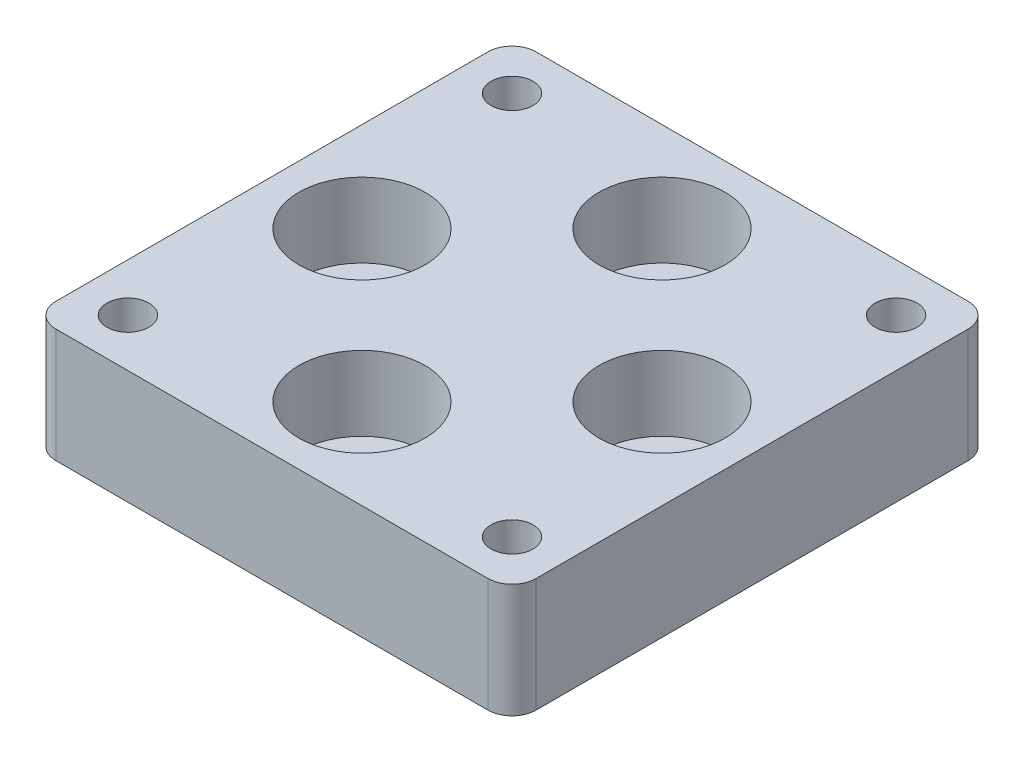
from build123d import *

# Parameters (mm, degrees)
SKETCH_1_W          = 40
SKETCH_1_H          = 40
SKETCH_1_R          = 1.75
SKETCH_1_R_2        = 3.1
EXTRUDE_1_DEPTH     = 9.5
FILLET_1_R          = 2
SKETCH_2_R          = 5.25
CUT_EXTRUDE_1_DEPTH = 6.2


with BuildPart() as part:
    # 草图1 → 凸台-拉伸1 (new body)
    with BuildSketch(Plane(origin=(0, 0, 0), x_dir=(1, 0, 0), z_dir=(0, 1, 0))):
        Rectangle(SKETCH_1_W, SKETCH_1_H)
        with Locations(Location((-16, 16, 0), (0, 0, 270))):  # turned: the seam where the file's is
            Circle(SKETCH_1_R, mode=Mode.SUBTRACT)
        with Locations(Location((16, 16, 0), (0, 0, 270))):  # turned: the seam where the file's is
            Circle(SKETCH_1_R, mode=Mode.SUBTRACT)
        with Locations(Location((-16, -16, 0), (0, 0, 270))):  # turned: the seam where the file's is
            Circle(SKETCH_1_R, mode=Mode.SUBTRACT)
        with Locations(Location((16, -16, 0), (0, 0, 270))):  # turned: the seam where the file's is
            Circle(SKETCH_1_R, mode=Mode.SUBTRACT)
        with Locations(Location((-12.5, 0, 0), (0, 0, 270))):  # turned: the seam where the file's is
            Circle(SKETCH_1_R_2, mode=Mode.SUBTRACT)
        with Locations(Location((12.5, 0, 0), (0, 0, 90))):  # turned: the seam where the file's is
            Circle(SKETCH_1_R_2, mode=Mode.SUBTRACT)
        with Locations(Location((0, 12.5, 0), (0, 0, 270))):  # turned: the seam where the file's is
            Circle(SKETCH_1_R_2, mode=Mode.SUBTRACT)
        with Locations(Location((0, -12.5, 0), (0, 0, 90))):  # turned: the seam where the file's is
            Circle(SKETCH_1_R_2, mode=Mode.SUBTRACT)
    extrude(amount=EXTRUDE_1_DEPTH)

    # 圆角1
    fillet_1_edges = [part.edges().sort_by_distance(p)[0] for p in [
        (20, 4.75, 20),
        (-20, 4.75, 20),
        (-20, 4.75, -20),
        (20, 4.75, -20),
    ]]
    fillet(fillet_1_edges, radius=FILLET_1_R)

    # 草图2 → 切除-拉伸1 (cut)
    with BuildSketch(Plane(origin=(0, 9.5, 0), x_dir=(1, 0, 0), z_dir=(0, 1, 0))):
        with Locations(Location((0, 12.5, 0), (0, 0, 270))):  # turned: the seam where the file's is
            Circle(SKETCH_2_R)
        with Locations(Location((12.5, 0, 0), (0, 0, 270))):  # turned: the seam where the file's is
            Circle(SKETCH_2_R)
        with Locations(Location((0, -12.5, 0), (0, 0, 270))):  # turned: the seam where the file's is
            Circle(SKETCH_2_R)
        with Locations(Location((-12.5, 0, 0), (0, 0, 270))):  # turned: the seam where the file's is
            Circle(SKETCH_2_R)
    extrude(amount=-CUT_EXTRUDE_1_DEPTH, mode=Mode.SUBTRACT)


solid = part.part
